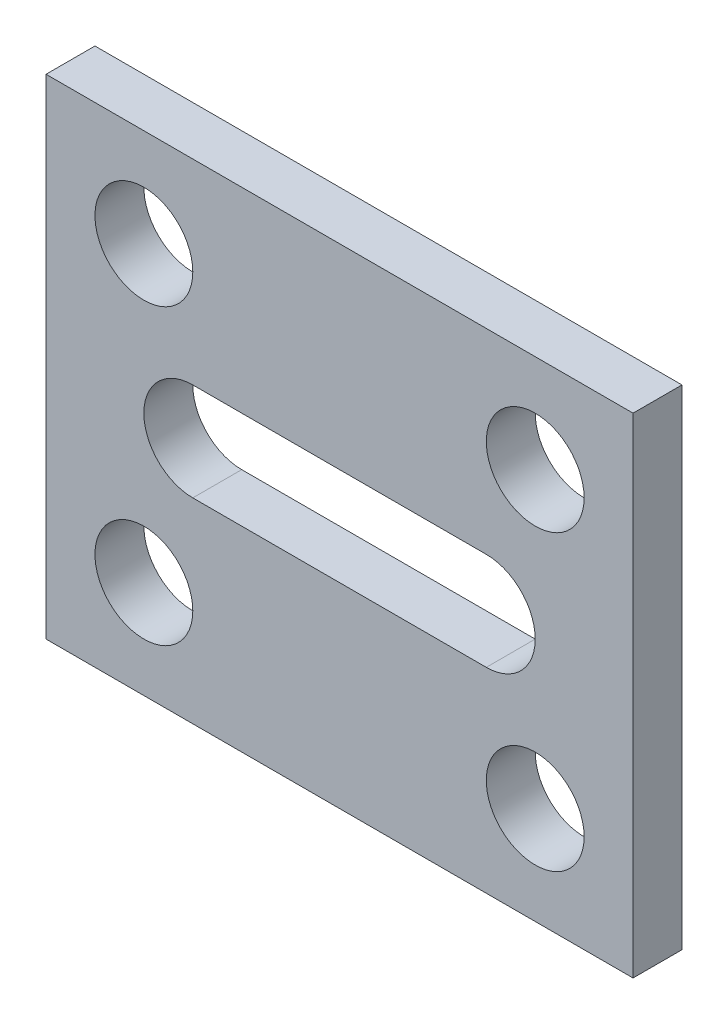
from build123d import *

# Parameters (mm, degrees)
SKETCH1_W           = 120
SKETCH1_H           = 100
SKETCH1_R           = 10
BOSS_EXTRUDE1_DEPTH = 10


with BuildPart() as part:
    # Sketch1 → Boss-Extrude1 (new body)
    with BuildSketch(Plane.XY):
        with Locations((60, 50)):
            Rectangle(SKETCH1_W, SKETCH1_H)
        with Locations((20, 80)):
            Circle(SKETCH1_R, mode=Mode.SUBTRACT)
        with Locations((100, 80)):
            Circle(SKETCH1_R, mode=Mode.SUBTRACT)
        with Locations((100, 20)):
            Circle(SKETCH1_R, mode=Mode.SUBTRACT)
        with Locations((20, 20)):
            Circle(SKETCH1_R, mode=Mode.SUBTRACT)
        with BuildLine():
            Line((30, 60), (90, 60))
            ThreePointArc((90, 60), (100, 50), (90, 40))
            Line((90, 40), (30, 40))
            ThreePointArc((30, 40), (20, 50), (30, 60))
        make_face(mode=Mode.SUBTRACT)
    extrude(amount=BOSS_EXTRUDE1_DEPTH)


solid = part.part
